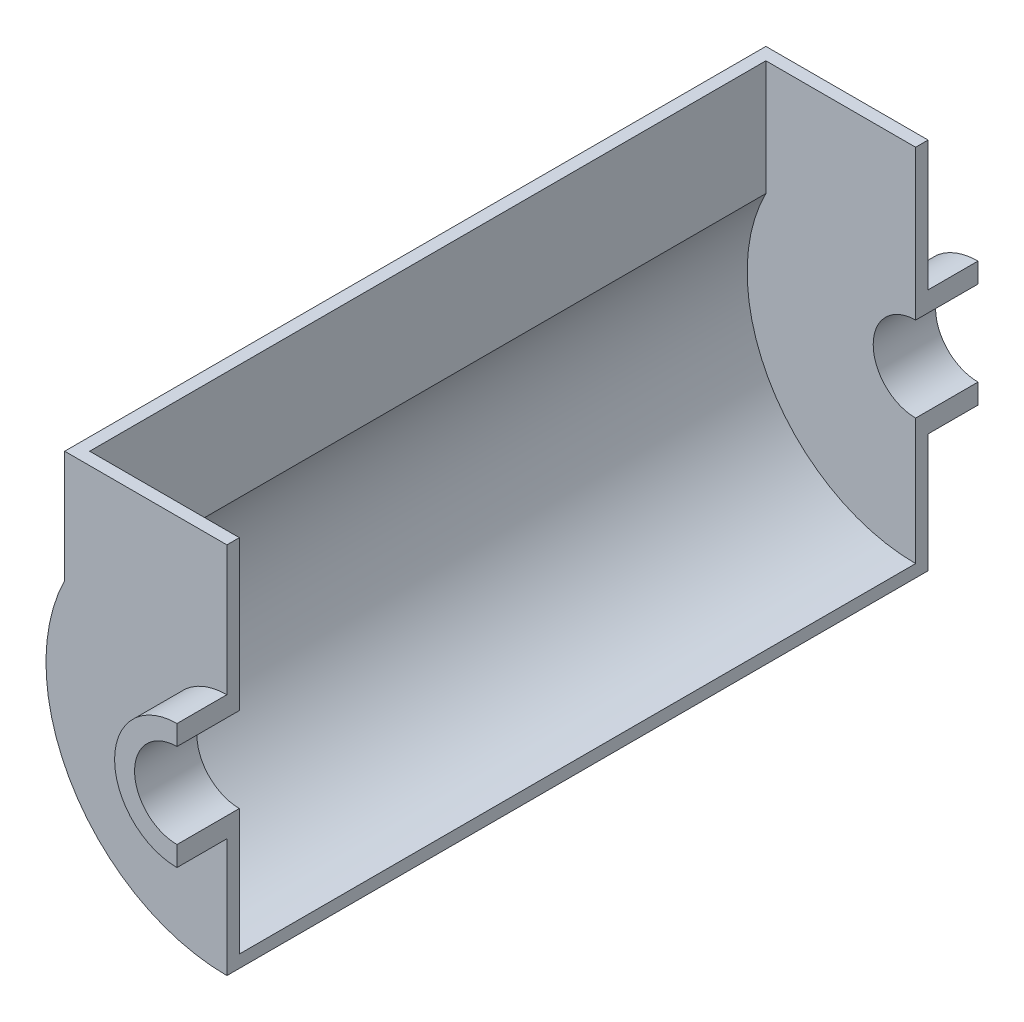
from build123d import *

# Parameters (mm, degrees)
BOSS_EXTRUDE1_DEPTH      = 20
BOSS_EXTRUDE1_DEPTH_BACK = 5
BOSS_EXTRUDE2_DEPTH      = 5
BOSS_EXTRUDE3_DEPTH      = 271


with BuildPart() as part:
    # Sketch1 → Boss-Extrude1 (new body, two sides)
    with BuildSketch(Plane.XY) as boss_extrude1_sk:
        with BuildLine():
            Line((0, 25), (0, 17))
            ThreePointArc((0, 17), (-17, 0), (0, -17))
            Line((0, -17), (0, -25))
            ThreePointArc((0, -25), (-25, 0), (0, 25))
        make_face()
    extrude(amount=BOSS_EXTRUDE1_DEPTH)
    extrude(boss_extrude1_sk.sketch, amount=-BOSS_EXTRUDE1_DEPTH_BACK)

    # Sketch2 → Boss-Extrude2 (add)
    with BuildSketch(Plane.XY):
        with BuildLine():
            Line((0, 25), (0, 77))
            Line((0, 77), (-65, 77))
            Line((-65, 77), (-65, 32.113081447))
            ThreePointArc((-65, 32.113081447), (-61.581037686, -38.262590053), (0, -72.5))
            Line((0, -72.5), (0, -25))
            ThreePointArc((0, -25), (-25, 0), (0, 25))
        make_face()
    extrude(amount=-BOSS_EXTRUDE2_DEPTH)


with BuildPart() as body_2:
    # Mirror1: mirrored copy
    add(part.part.mirror(Plane.XY.offset(-140.5)))


with BuildPart() as part_1:
    add(part.part)

    add(body_2.part)  # Boss-Extrude3 merges body 2
    # Sketch3 → Boss-Extrude3 (add)
    with BuildSketch(Plane(origin=(0, 0, -5), x_dir=(-1, 0, 0), z_dir=(0, 0, -1))):
        with BuildLine():
            Line((65, 77), (65, 32.113081447))
            ThreePointArc((65, 32.113081447), (61.581037686, -38.262590053), (0, -72.5))
            Line((0, -72.5), (0, -67.5))
            ThreePointArc((0, -67.5), (57.634938288, -35.134938288), (60, 30.923292192))
            Line((60, 30.923292192), (60, 77))
            Line((60, 77), (65, 77))
        make_face()
    extrude(amount=BOSS_EXTRUDE3_DEPTH)


solid = part_1.part
